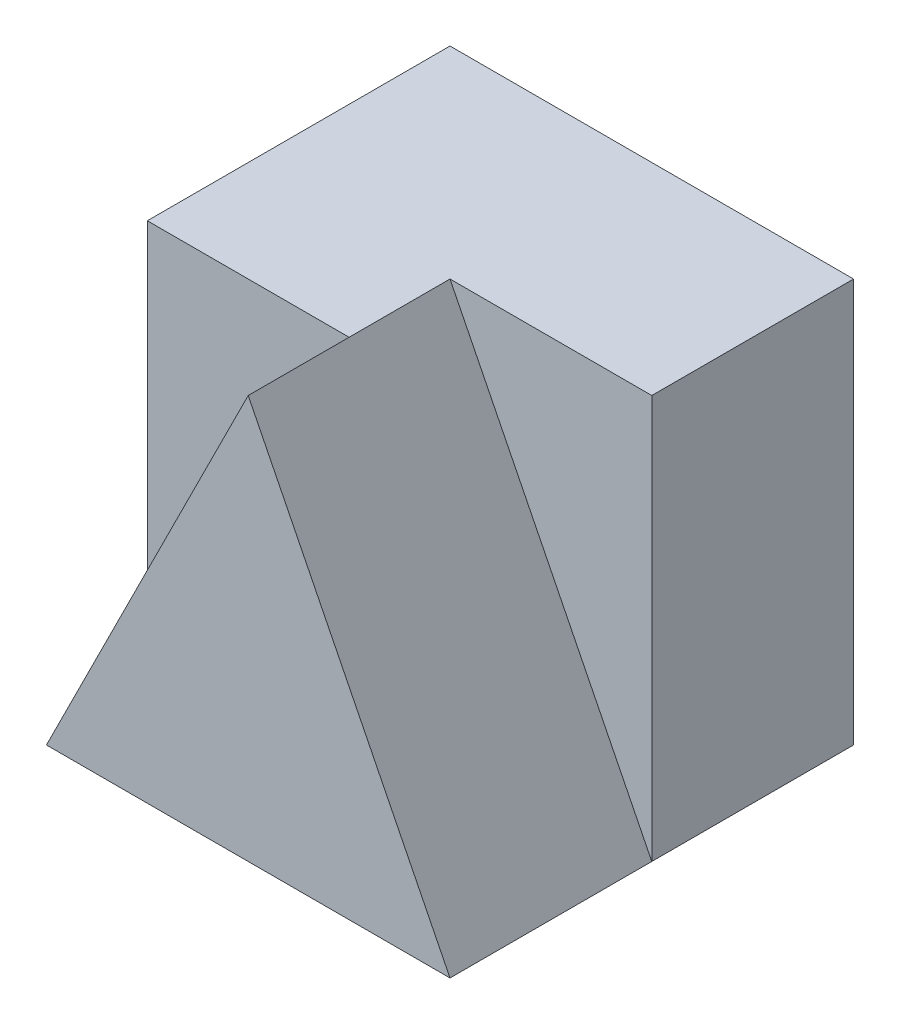
from build123d import *

# Parameters (mm, degrees)
SKETCH1_W           = 4
SKETCH1_H           = 4
BOSS_EXTRUDE1_DEPTH = 4
CUT_EXTRUDE1_DEPTH  = 2
CUT_EXTRUDE2_DEPTH  = 1


with BuildPart() as part:
    # Sketch1 → Boss-Extrude1 (new body)
    with BuildSketch(Plane(origin=(0, 0, 0), x_dir=(1, 0, 0), z_dir=(0, 1, 0))):
        Rectangle(SKETCH1_W, SKETCH1_H)
    extrude(amount=BOSS_EXTRUDE1_DEPTH)

    # Sketch4 → Cut-Extrude1 (cut)
    with BuildSketch(Plane.XY.offset(2)):
        Polygon((0, 4), (2, 4), (2, 0), align=None)
    extrude(amount=-CUT_EXTRUDE1_DEPTH, mode=Mode.SUBTRACT)

    # Sketch5 → Cut-Extrude2 (cut)
    with BuildSketch(Plane.XY.offset(2)):
        Polygon((0, 4), (-2, 0), (-2, 4), align=None)
    extrude(amount=-CUT_EXTRUDE2_DEPTH, mode=Mode.SUBTRACT)


solid = part.part
